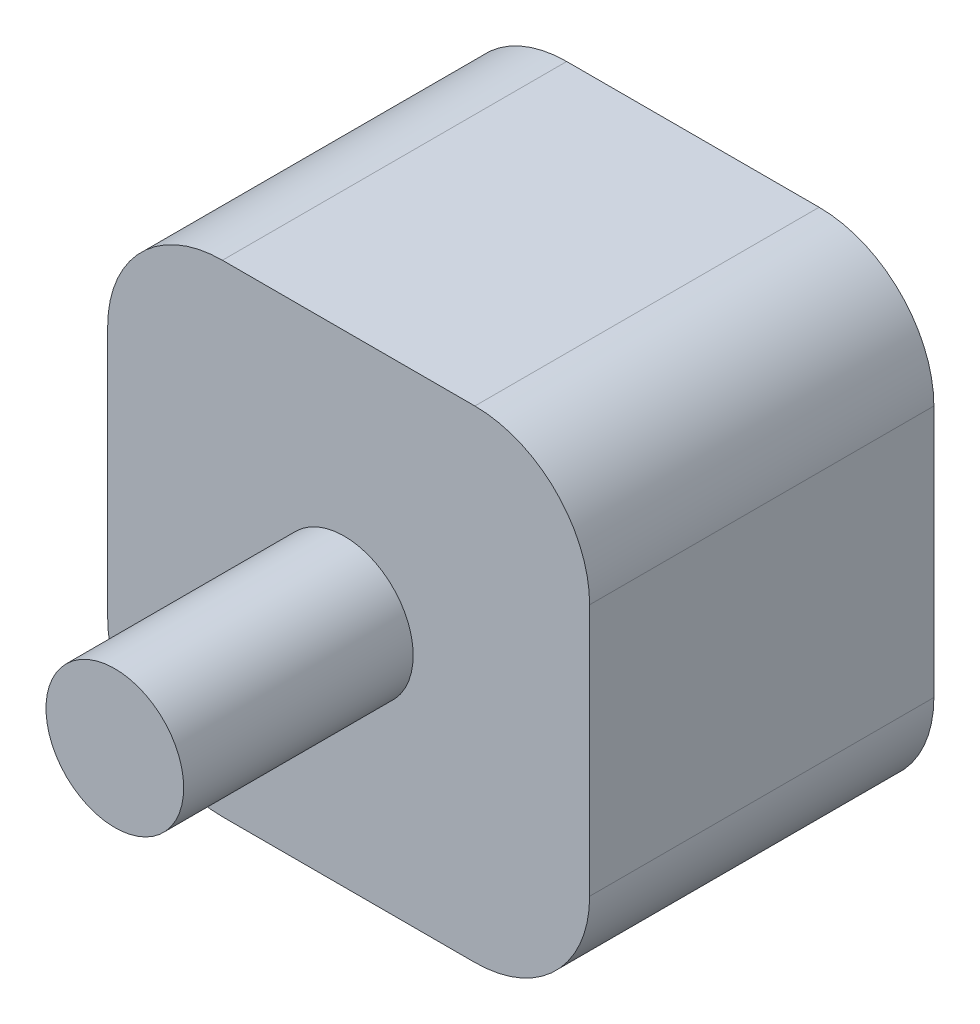
from build123d import *

# Parameters (mm, degrees)
SKETCH_1_W      = 42
SKETCH_1_H      = 42
EXTRUDE_1_DEPTH = 30
SKETCH_2_R      = 6
EXTRUDE_2_DEPTH = 20
FILLET_2_R      = 10
FILLET_3_R      = 10
FILLET_4_R      = 10
FILLET_5_R      = 10


with BuildPart() as part:
    # 草图1 → 凸台-拉伸1 (new body)
    with BuildSketch(Plane.XY):
        with Locations((0.376569841, 0.510488218)):
            Rectangle(SKETCH_1_W, SKETCH_1_H)
    extrude(amount=EXTRUDE_1_DEPTH)

    # 圆角2
    fillet_2_edges = [part.edges().sort_by_distance(p)[0] for p in [
        (21.376569841, 21.510488218, 15),
    ]]
    fillet(fillet_2_edges, radius=FILLET_2_R)

    # 圆角3
    fillet_3_edges = [part.edges().sort_by_distance(p)[0] for p in [
        (-20.623430159, 21.510488218, 15),
    ]]
    fillet(fillet_3_edges, radius=FILLET_3_R)

    # 圆角4
    fillet_4_edges = [part.edges().sort_by_distance(p)[0] for p in [
        (-20.623430159, -20.489511782, 15),
    ]]
    fillet(fillet_4_edges, radius=FILLET_4_R)

    # 圆角5
    fillet_5_edges = [part.edges().sort_by_distance(p)[0] for p in [
        (21.376569841, -20.489511782, 15),
    ]]
    fillet(fillet_5_edges, radius=FILLET_5_R)


with BuildPart() as body_2:
    # 草图2 → 凸台-拉伸2 (new body)
    with BuildSketch(Plane.XY.offset(30)):
        Circle(SKETCH_2_R)
    extrude(amount=EXTRUDE_2_DEPTH)


solid = Compound([part.part, body_2.part])
